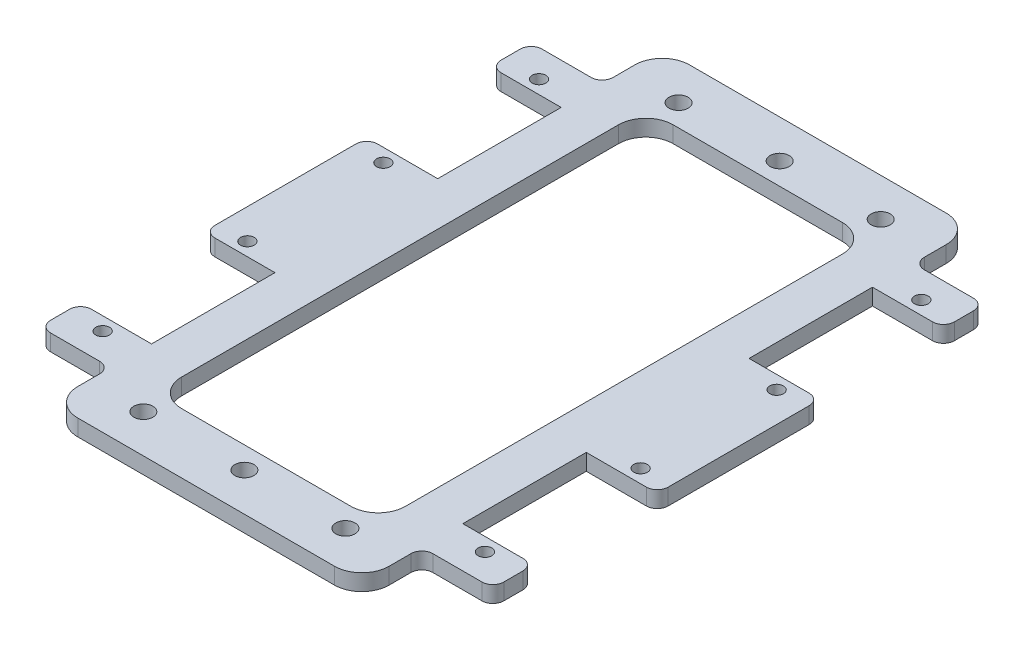
from build123d import *

# Parameters (mm, degrees)
SKETCH_1_W      = 41
SKETCH_1_H      = 90
SKETCH_1_R      = 1.25
SKETCH_1_R_2    = 1.75
EXTRUDE_1_DEPTH = 3
FILLET_1_R      = 2
FILLET_2_R      = 5
FILLET_3_R      = 2


with BuildPart() as part:
    # 草图1 → 凸台-拉伸1 (new body)
    with BuildSketch(Plane(origin=(0, 0, 0), x_dir=(1, 0, 0), z_dir=(0, 1, 0))):
        Polygon((-28.5, -37.5), (-41.5, -37.5), (-41.5, -45), (-28.5, -45), (-28.5, -56), (28.5, -56), (28.5, -45), (41.5, -45), (41.5, -37.5), (28.5, -37.5), (28.5, -14.9), (41.5, -14.9), (41.5, 14.9), (28.5, 14.9), (28.5, 37.5), (41.5, 37.5), (41.5, 45), (28.5, 45), (28.5, 56), (-28.5, 56), (-28.5, 45), (-41.5, 45), (-41.5, 37.5), (-28.5, 37.5), (-28.5, 14.9), (-41.5, 14.9), (-41.5, -14.9), (-28.5, -14.9), align=None)
        Rectangle(SKETCH_1_W, SKETCH_1_H, mode=Mode.SUBTRACT)
        with Locations((-35, -39.95)):
            Circle(SKETCH_1_R, mode=Mode.SUBTRACT)
        with Locations((18.5, -49)):
            Circle(SKETCH_1_R_2, mode=Mode.SUBTRACT)
        with Locations((-18.5, -49)):
            Circle(SKETCH_1_R_2, mode=Mode.SUBTRACT)
        with Locations((-36, 12.45)):
            Circle(SKETCH_1_R, mode=Mode.SUBTRACT)
        with Locations((-36, -12.45)):
            Circle(SKETCH_1_R, mode=Mode.SUBTRACT)
        with Locations((0, -49)):
            Circle(SKETCH_1_R_2, mode=Mode.SUBTRACT)
        with Locations((18.5, 49)):
            Circle(SKETCH_1_R_2, mode=Mode.SUBTRACT)
        with Locations((-18.5, 49)):
            Circle(SKETCH_1_R_2, mode=Mode.SUBTRACT)
        with Locations((0, 49)):
            Circle(SKETCH_1_R_2, mode=Mode.SUBTRACT)
        with Locations((-35, 39.95)):
            Circle(SKETCH_1_R, mode=Mode.SUBTRACT)
        with Locations((35, 39.95)):
            Circle(SKETCH_1_R, mode=Mode.SUBTRACT)
        with Locations((35, -39.95)):
            Circle(SKETCH_1_R, mode=Mode.SUBTRACT)
        with Locations((36, 12.45)):
            Circle(SKETCH_1_R, mode=Mode.SUBTRACT)
        with Locations((36, -12.45)):
            Circle(SKETCH_1_R, mode=Mode.SUBTRACT)
    extrude(amount=EXTRUDE_1_DEPTH)

    # 圆角1
    fillet_1_edges = [part.edges().sort_by_distance(p)[0] for p in [
        (-41.5, 1.5, 45),
        (-41.5, 1.5, 37.5),
        (-41.5, 1.5, 14.9),
        (-41.5, 1.5, -14.9),
        (-41.5, 1.5, -37.5),
        (-41.5, 1.5, -45),
        (41.5, 1.5, -45),
        (41.5, 1.5, -37.5),
        (41.5, 1.5, -14.9),
        (41.5, 1.5, 14.9),
        (41.5, 1.5, 37.5),
        (41.5, 1.5, 45),
    ]]
    fillet(fillet_1_edges, radius=FILLET_1_R)

    # 圆角2
    fillet_2_edges = [part.edges().sort_by_distance(p)[0] for p in [
        (28.5, 1.5, 56),
        (-28.5, 1.5, 56),
        (-28.5, 1.5, -56),
        (28.5, 1.5, -56),
        (20.5, 1.5, 45),
        (20.5, 1.5, -45),
        (-20.5, 1.5, -45),
        (-20.5, 1.5, 45),
    ]]
    fillet(fillet_2_edges, radius=FILLET_2_R)

    # 圆角3
    fillet_3_edges = [part.edges().sort_by_distance(p)[0] for p in [
        (-28.5, 1.5, 45),
        (-28.5, 1.5, -45),
        (28.5, 1.5, -45),
        (28.5, 1.5, 45),
    ]]
    fillet(fillet_3_edges, radius=FILLET_3_R)


solid = part.part
